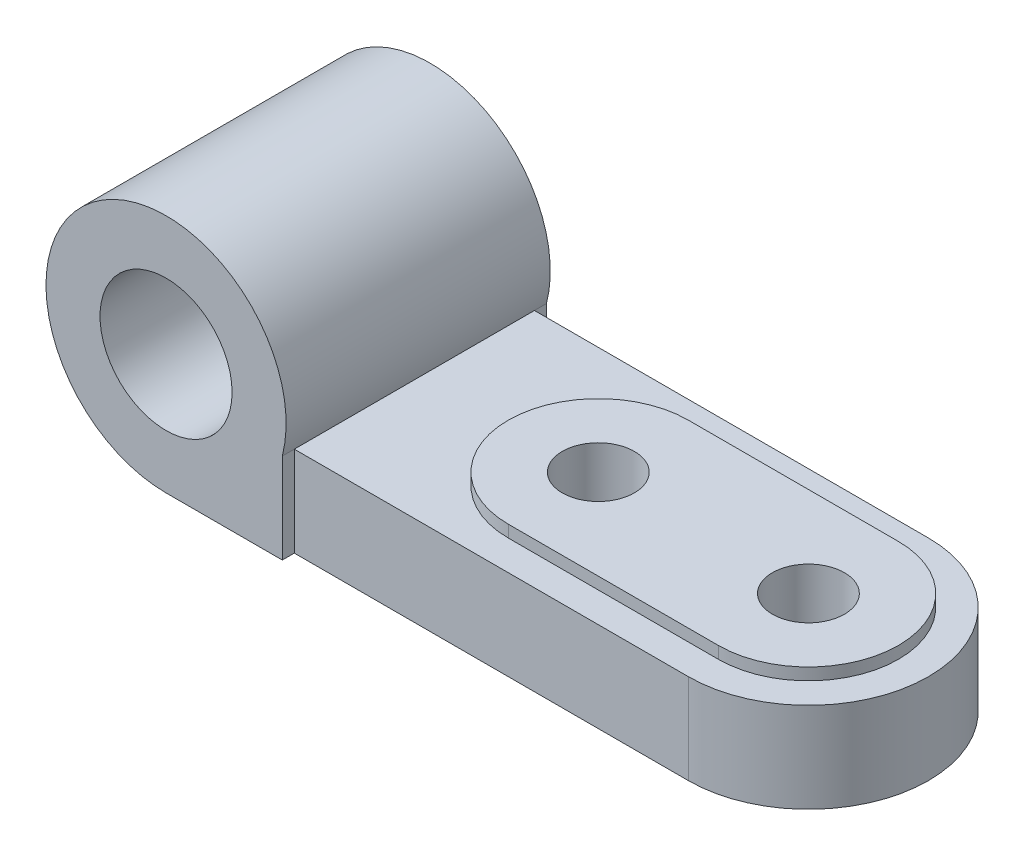
from build123d import *

# Parameters (mm, degrees)
SKETCH1_R           = 11
BOSS_EXTRUDE1_DEPTH = 44
BOSS_EXTRUDE2_DEPTH = 44
CUT_EXTRUDE1_DEPTH  = 44
BOSS_EXTRUDE3_DEPTH = 2
SKETCH4_R           = 6
CUT_EXTRUDE2_DEPTH  = 44


with BuildPart() as part:
    # Sketch1 → Boss-Extrude1 (new body)
    with BuildSketch(Plane.XY):
        with BuildLine():
            ThreePointArc((-37.809139785, 0), (-71.951275409, 14.142135624), (-57.809139785, -20))
            ThreePointArc((-57.809139785, -20), (-45.561691071, -15.811388301), (-38.444223054, -5))
            ThreePointArc((-38.444223054, -5), (-37.96854586, -2.52008585), (-37.809139785, 0))
        make_face()
        with Locations((-57.809139785, 0)):
            Circle(SKETCH1_R, mode=Mode.SUBTRACT)
    extrude(amount=BOSS_EXTRUDE1_DEPTH)

    # Sketch1_5 → Boss-Extrude2 (add)
    with BuildSketch(Plane.XY):
        with BuildLine():
            ThreePointArc((-38.444223054, -5), (-45.561691071, -15.811388301), (-57.809139785, -20))
            Line((-57.809139785, -20), (47.190860215, -20))
            Line((47.190860215, -20), (47.190860215, -5))
            Line((47.190860215, -5), (-38.444223054, -5))
        make_face()
    extrude(amount=BOSS_EXTRUDE2_DEPTH)

    # Sketch2 → Cut-Extrude1 (cut)
    with BuildSketch(Plane(origin=(0, -5, 0), x_dir=(1, 0, 0), z_dir=(0, 1, 0))):
        with BuildLine():
            Line((47.190860215, 0), (-38.444223054, 0))
            Line((-38.444223054, 0), (-38.444223054, -2))
            Line((-38.444223054, -2), (27.190860215, -2))
            ThreePointArc((27.190860215, -2), (41.332995839, -7.857864376), (47.190860215, -22))
            Line((47.190860215, -22), (47.190860215, 0))
        make_face()
        with BuildLine():
            Line((27.190860215, -42), (-38.444223054, -42))
            Line((-38.444223054, -42), (-38.444223054, -44))
            Line((-38.444223054, -44), (47.190860215, -44))
            Line((47.190860215, -44), (47.190860215, -22))
            ThreePointArc((47.190860215, -22), (41.332995839, -36.142135624), (27.190860215, -42))
        make_face()
    extrude(amount=-CUT_EXTRUDE1_DEPTH, mode=Mode.SUBTRACT)

    # Sketch3 → Boss-Extrude3 (add)
    with BuildSketch(Plane(origin=(0, -5, 0), x_dir=(1, 0, 0), z_dir=(0, 1, 0))):
        with BuildLine():
            Line((-7.809139785, -37), (27.190860215, -37))
            ThreePointArc((27.190860215, -37), (42.190860215, -22), (27.190860215, -7))
            Line((27.190860215, -7), (-7.809139785, -7))
            ThreePointArc((-7.809139785, -7), (-22.809139785, -22), (-7.809139785, -37))
        make_face()
    extrude(amount=BOSS_EXTRUDE3_DEPTH)

    # Sketch4 → Cut-Extrude2 (cut)
    with BuildSketch(Plane(origin=(0, -3, 0), x_dir=(1, 0, 0), z_dir=(0, 1, 0))):
        with Locations((27.190860215, -22)):
            Circle(SKETCH4_R)
        with Locations((-7.809139785, -22)):
            Circle(SKETCH4_R)
    extrude(amount=-CUT_EXTRUDE2_DEPTH, mode=Mode.SUBTRACT)


solid = part.part
